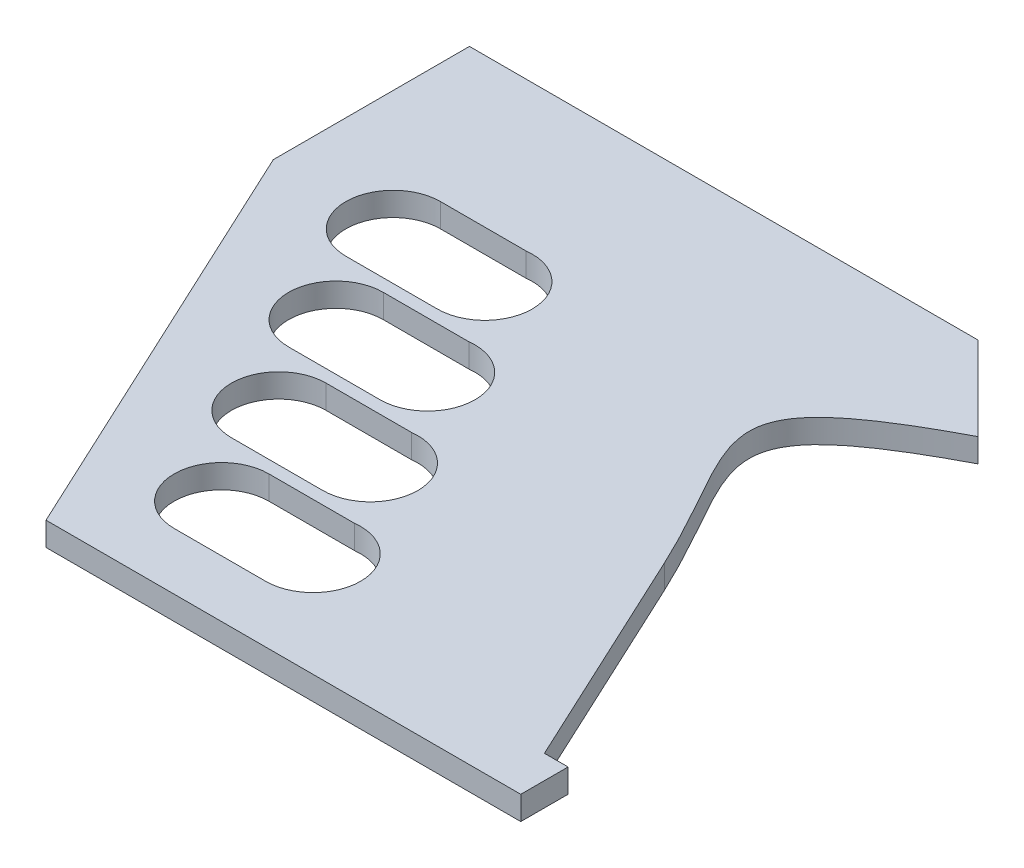
from build123d import *

# Parameters (mm, degrees)
BOSS_EXTRUDE1_DEPTH = 5
CUT_EXTRUDE1_DEPTH  = 5
CRVPATTERN1_COUNT   = 4
CRVPATTERN1_PITCH   = 25


with BuildPart() as part:
    # Sketch1 → Boss-Extrude1 (new body)
    with BuildSketch(Plane(origin=(0, 0, 0), x_dir=(1, 0, 0), z_dir=(0, 1, 0))):
        with BuildLine():
            Line((29.424030449, 17.67766953), (-78.052582598, 17.67766953))
            Line((-78.052582598, 17.67766953), (-78.052582598, -23.77998841))
            Line((-78.052582598, -23.77998841), (-36.084893364, -113.77998841))
            Line((-36.084893364, -113.77998841), (64.252030054, -113.77998841))
            Line((64.252030054, -113.77998841), (64.252030054, -103.77998841))
            Line((64.252030054, -103.77998841), (59.252030054, -103.77998841))
            Line((59.252030054, -103.77998841), (37.104377349, -56.284193911))
            add(Edge.make_bspline(
                [(47.101699979, 0), (7.916375449, -20.532992836), (22.607602938, -25.195760862), (37.104377349, -56.284193911)],
                knots=[0, 0, 0, 0, 1, 1, 1, 1], degree=3))
            Line((47.101699979, 0), (29.424030449, 17.67766953))
        make_face()
    extrude(amount=BOSS_EXTRUDE1_DEPTH)

    # Sketch2 → Cut-Extrude1 (cut)
    with BuildSketch(Plane(origin=(0, 5, 0), x_dir=(1, 0, 0), z_dir=(0, 1, 0))):
        with BuildLine():
            Line((-52.71565918, -13.77998841), (-42.71565918, -13.77998841))
            Line((-42.71565918, -13.77998841), (-34.610479114, -13.77998841))
            ThreePointArc((-34.610479114, -13.77998841), (-23.370888656, -23.131095914), (-33.389506017, -33.77998841))
            Line((-33.389506017, -33.77998841), (-43.389506017, -33.77998841))
            Line((-43.389506017, -33.77998841), (-52.71565918, -33.77998841))
            ThreePointArc((-52.71565918, -33.77998841), (-62.71565918, -23.77998841), (-52.71565918, -13.77998841))
        make_face()
    cut_extrude1 = extrude(amount=-CUT_EXTRUDE1_DEPTH, mode=Mode.SUBTRACT)

    # CrvPattern1: Cut-Extrude1 ×4
    with Locations(*[Vector(0.4226182619677251, 0, 0.9063077869307863) * (i * CRVPATTERN1_PITCH) for i in range(1, CRVPATTERN1_COUNT)]):
        add(cut_extrude1, mode=Mode.SUBTRACT)


solid = part.part
